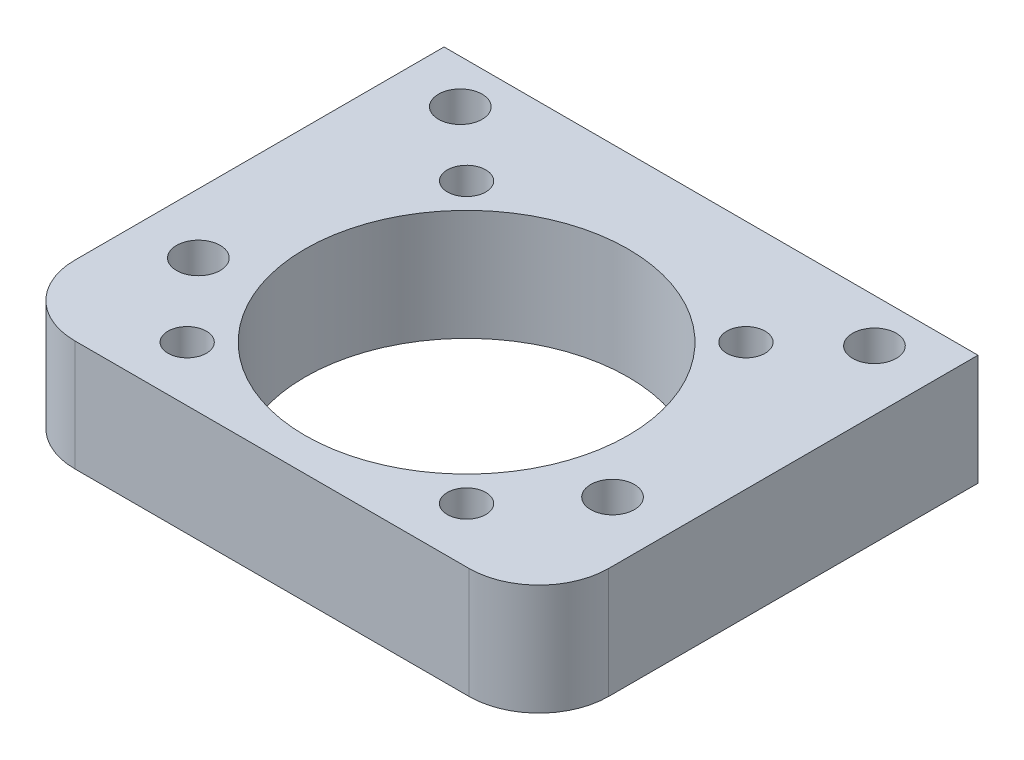
from build123d import *

# Parameters (mm, degrees)
BOSS_EXTRUDE1_DEPTH              = 6.35
F_2_2_2_2_DIAMETER_HOLE1_D       = 2.2
F_2_2_2_2_DIAMETER_HOLE1_DEPTH   = 6.35
F_2_2_2_2_DIAMETER_HOLE2_D       = 2.2
F_2_2_2_2_DIAMETER_HOLE2_DEPTH   = 6.35
F_2_2_2_2_DIAMETER_HOLE3_D       = 2.2
F_2_2_2_2_DIAMETER_HOLE3_DEPTH   = 6.35
F_2_2_2_2_DIAMETER_HOLE4_D       = 2.2
F_2_2_2_2_DIAMETER_HOLE4_DEPTH   = 6.35
F_18_5_18_5_DIAMETER_HOLE1_D     = 18.5
F_18_5_18_5_DIAMETER_HOLE1_DEPTH = 6.35
M3_TAPPED_HOLE1_D                = 2.5
M3_TAPPED_HOLE2_D                = 2.5
M3_TAPPED_HOLE3_D                = 2.5
M3_TAPPED_HOLE4_D                = 2.5


with BuildPart() as part:
    # Sketch1 → Boss-Extrude1 (new body)
    with BuildSketch(Plane(origin=(0, 6.35, 0), x_dir=(1, 0, 0), z_dir=(0, 1, 0))):
        with BuildLine():
            Line((15.288980095, -7.15), (15.288980095, 14))
            Line((15.288980095, 14), (-15.289019905, 14))
            Line((-15.289019905, 14), (-15.289019905, -7.15))
            ThreePointArc((-15.289019905, -7.15), (-14.11744703, -9.978427125), (-11.289019905, -11.15))
            Line((-11.289019905, -11.15), (11.288980095, -11.15))
            ThreePointArc((11.288980095, -11.15), (14.11740722, -9.978427125), (15.288980095, -7.15))
        make_face()
    extrude(amount=-BOSS_EXTRUDE1_DEPTH)

    # Ø2.2 (2.2) Diameter Hole1
    with Locations(Plane(origin=(0, 0, 0), x_dir=(-1, 0, 0), z_dir=(0, -1, 0))):
        with Locations((-7.999980095, -8)):
            Hole(F_2_2_2_2_DIAMETER_HOLE1_D / 2, depth=F_2_2_2_2_DIAMETER_HOLE1_DEPTH)

    # Ø2.2 (2.2) Diameter Hole2
    with Locations(Plane(origin=(0, 0, 0), x_dir=(-1, 0, 0), z_dir=(0, -1, 0))):
        with Locations((8.000019905, 8)):
            Hole(F_2_2_2_2_DIAMETER_HOLE2_D / 2, depth=F_2_2_2_2_DIAMETER_HOLE2_DEPTH)

    # Ø2.2 (2.2) Diameter Hole3
    with Locations(Plane(origin=(0, 0, 0), x_dir=(-1, 0, 0), z_dir=(0, -1, 0))):
        with Locations((-7.999980095, 8)):
            Hole(F_2_2_2_2_DIAMETER_HOLE3_D / 2, depth=F_2_2_2_2_DIAMETER_HOLE3_DEPTH)

    # Ø2.2 (2.2) Diameter Hole4
    with Locations(Plane(origin=(0, 6.35, 0), x_dir=(1, 0, 0), z_dir=(0, 1, 0))):
        with Locations((-8.000019905, -8)):
            Hole(F_2_2_2_2_DIAMETER_HOLE4_D / 2, depth=F_2_2_2_2_DIAMETER_HOLE4_DEPTH)

    # Ø18.5 (18.5) Diameter Hole1
    with Locations(Plane(origin=(0, 0, 0), x_dir=(-1, 0, 0), z_dir=(0, -1, 0))):
        with Locations((0, 0)):
            Hole(F_18_5_18_5_DIAMETER_HOLE1_D / 2, depth=F_18_5_18_5_DIAMETER_HOLE1_DEPTH)

    # M3 Tapped Hole1 (through all)
    with Locations(Plane(origin=(0, 0, 0), x_dir=(-1, 0, 0), z_dir=(0, -1, 0))):
        with Locations((11.858637076, 11.5)):
            Hole(M3_TAPPED_HOLE1_D / 2)

    # M3 Tapped Hole2 (through all)
    with Locations(Plane(origin=(0, 0, 0), x_dir=(-1, 0, 0), z_dir=(0, -1, 0))):
        with Locations((11.85956559, -3.500033723)):
            Hole(M3_TAPPED_HOLE2_D / 2)

    # M3 Tapped Hole3 (through all)
    with Locations(Plane(origin=(0, 0, 0), x_dir=(-1, 0, 0), z_dir=(0, -1, 0))):
        with Locations((-11.858647005, 11.5)):
            Hole(M3_TAPPED_HOLE3_D / 2)

    # M3 Tapped Hole4 (through all)
    with Locations(Plane(origin=(0, 0, 0), x_dir=(-1, 0, 0), z_dir=(0, -1, 0))):
        with Locations((-11.859575542, -3.5)):
            Hole(M3_TAPPED_HOLE4_D / 2)


solid = part.part
